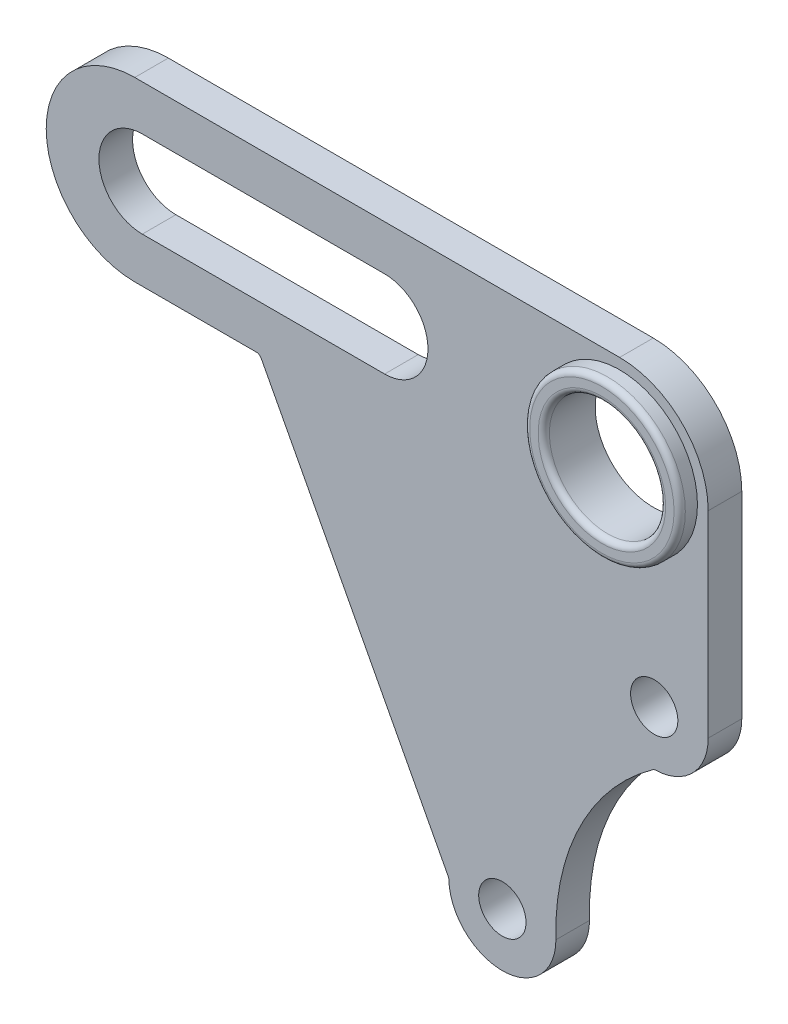
from build123d import *

# Parameters (mm, degrees)
SKETCH2_R           = 4.195
SKETCH2_R_2         = 10.305
BOSS_EXTRUDE1_DEPTH = 5.96
FILLET1_R           = 1
SKETCH3_R           = 13.8
SKETCH3_R_2         = 10.305
BOSS_EXTRUDE2_DEPTH = 3.15
FILLET2_R           = 1


with BuildPart() as part:
    # Sketch2 → Boss-Extrude1 (new body)
    with BuildSketch(Plane.XY):
        with BuildLine():
            Line((101.69, 0), (101.69, 15.7))
            ThreePointArc((101.69, 15.7), (97.091576465, 26.801576465), (85.99, 31.4))
            Line((85.99, 31.4), (0, 31.4))
            ThreePointArc((0, 31.4), (-11.101576465, 26.801576465), (-15.7, 15.7))
            ThreePointArc((-15.7, 15.7), (-11.101576465, 4.598423535), (0, 0))
            Line((0, 0), (22.15, 0))
            Line((22.15, 0), (55.695, -63.695))
            ThreePointArc((55.695, -63.695), (58.476021113, -70.408978887), (65.19, -73.19))
            ThreePointArc((65.19, -73.19), (71.903978887, -70.408978887), (74.685, -63.695))
            ThreePointArc((74.685, -63.695), (74.678632674, -63.462256539), (74.673581437, -63.229480796))
            ThreePointArc((74.673581437, -63.229480796), (79.11133413, -43.842864153), (92.1177, -28.7973))
            ThreePointArc((92.1177, -28.7973), (98.886338242, -25.993638242), (101.69, -19.225))
            Line((101.69, -19.225), (101.69, -12.489796776))
            Line((101.69, -12.489796776), (101.69, 0))
        make_face()
        with BuildLine():
            ThreePointArc((69.385, -63.695), (68.156312947, -66.661312947), (65.19, -67.89))
            ThreePointArc((65.19, -67.89), (62.223687053, -60.728687053), (69.385, -63.695))
        make_face(mode=Mode.SUBTRACT)
        with BuildLine():
            ThreePointArc((1.34, 8.01), (-4.097651147, 10.262348853), (-6.35, 15.7))
            ThreePointArc((-6.35, 15.7), (-4.097651147, 21.137651147), (1.34, 23.39))
            Line((1.34, 23.39), (44.31, 23.39))
            ThreePointArc((44.31, 23.39), (52, 15.7), (44.31, 8.01))
            Line((44.31, 8.01), (1.34, 8.01))
        make_face(mode=Mode.SUBTRACT)
        with Locations((92.1177, -19.225)):
            Circle(SKETCH2_R, mode=Mode.SUBTRACT)
        with Locations((85.99, 15.7)):
            Circle(SKETCH2_R_2, mode=Mode.SUBTRACT)
    extrude(amount=BOSS_EXTRUDE1_DEPTH)

    # Fillet1
    fillet1_edges = [part.edges().sort_by_distance(p)[0] for p in [
        (92.1177, -28.7973, 2.98),
        (55.695, -63.695, 2.98),
        (22.15, 0, 2.98),
    ]]
    fillet(fillet1_edges, radius=FILLET1_R)

    # Sketch3 → Boss-Extrude2 (add)
    with BuildSketch(Plane.XY.offset(5.96)):
        with Locations((85.99, 15.7)):
            Circle(SKETCH3_R)
        with Locations((85.99, 15.7)):
            Circle(SKETCH3_R_2, mode=Mode.SUBTRACT)
    extrude(amount=BOSS_EXTRUDE2_DEPTH)

    # Fillet2
    fillet2_edges = [part.edges().sort_by_distance(p)[0] for p in [
        (72.19, 15.7, 9.11),
        (75.685, 15.7, 9.11),
    ]]
    fillet(fillet2_edges, radius=FILLET2_R)


solid = part.part
